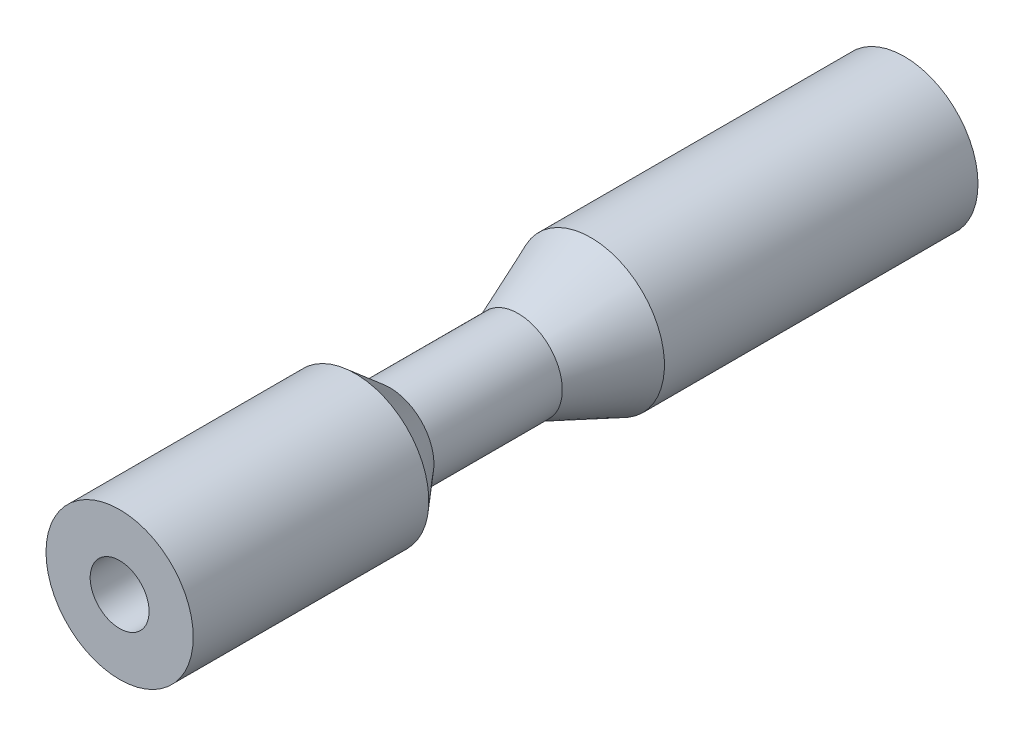
from build123d import *

# Parameters (mm, degrees)
SKETCH1_R                    = 2.5
BOSS_EXTRUDE1_DEPTH          = 27
CHAMFER1_SIZE                = 2
CHAMFER1_SIZE2               = 0.352653961
F_2_0_2_DIAMETER_HOLE1_D     = 2
F_2_0_2_DIAMETER_HOLE1_DEPTH = 26
F_2_0_2_DIAMETER_HOLE1_TIP   = 0.600860619
CUT_EXTRUDE1_REACH           = 29
SKETCH6_R                    = 0.25


with BuildPart() as part:
    # Sketch1 → Boss-Extrude1 (new body)
    with BuildSketch(Plane.XY):
        Circle(SKETCH1_R)
    extrude(amount=BOSS_EXTRUDE1_DEPTH)

    # Sketch3 → Cut-Revolve1 (revolve, cut)
    with BuildSketch(Plane(origin=(0, 0, 0), x_dir=(1, 0, 0), z_dir=(0, 1, 0))):
        Polygon((2.5, -11), (1.5, -13.467842271), (1.5, -17.827676266), (2.5, -19), (3.138230266, -19), (3.138230266, -11), align=None)
    revolve(axis=Axis((0, 0, 0), (0, 0, 1)), mode=Mode.SUBTRACT)

    # Chamfer1
    chamfer1_edges = [part.edges().sort_by_distance(p)[0] for p in [
        (-2.5, 0, 0),
    ]]
    chamfer1_side = [part.faces().sort_by_distance(p)[0] for p in [
        (0, 0, 0),
    ]]
    chamfer(chamfer1_edges, length=CHAMFER1_SIZE, length2=CHAMFER1_SIZE2, reference=chamfer1_side[0])

    # Ø2.0 (2) Diameter Hole1
    with Locations(Plane.XY.offset(27)):
        with Locations((0, 0)):
            Hole(F_2_0_2_DIAMETER_HOLE1_D / 2, depth=F_2_0_2_DIAMETER_HOLE1_DEPTH)
            with Locations((0, 0, -(F_2_0_2_DIAMETER_HOLE1_DEPTH + F_2_0_2_DIAMETER_HOLE1_TIP / 2))):  # 118° drill point
                Cone(0, F_2_0_2_DIAMETER_HOLE1_D / 2, F_2_0_2_DIAMETER_HOLE1_TIP, mode=Mode.SUBTRACT)

    # Sketch6 → Cut-Extrude1 (cut, up to next)
    with BuildSketch(Plane(origin=(0, 0, 0), x_dir=(-1, 0, 0), z_dir=(0, 0, -1)), mode=Mode.PRIVATE) as cut_extrude1_sk1:
        Circle(SKETCH6_R)
    cut_extrude1_tool1 = extrude(cut_extrude1_sk1.sketch, amount=-CUT_EXTRUDE1_REACH, mode=Mode.PRIVATE) & part.part
    add(cut_extrude1_tool1.solids().sort_by_distance((0, 0, 0))[0], mode=Mode.SUBTRACT)


solid = part.part
